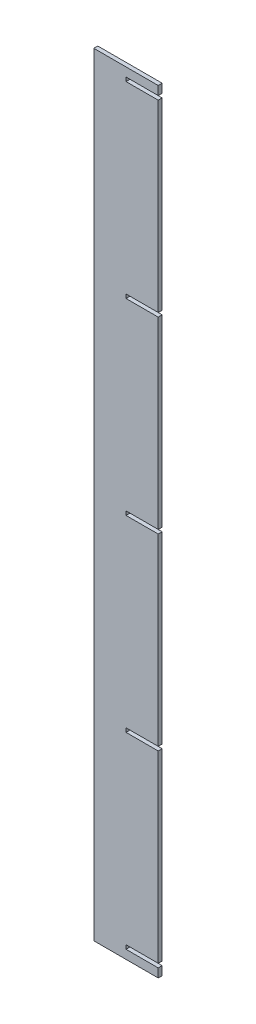
from build123d import *

# Parameters (mm, degrees)
BOSS_EXTRUDE1_DEPTH = 9.398


with BuildPart() as part:
    # Sketch1 → Boss-Extrude1 (new body)
    with BuildSketch(Plane.XY):
        Polygon((25084.546523942, 8828.751571885), (25084.546523942, 6999.951571885), (25236.946523942, 6999.951571885), (25236.946523942, 7020.652571885), (25160.746523942, 7020.652571885), (25160.746523942, 7030.050571885), (25236.946523942, 7030.050571885), (25236.946523942, 7465.152571885), (25160.746523942, 7465.152571885), (25160.746523942, 7474.550571885), (25236.946523942, 7474.550571885), (25236.946523942, 7909.652571885), (25160.746523942, 7909.652571885), (25160.746523942, 7919.050571885), (25236.946523942, 7919.050571885), (25236.946523942, 8354.152571885), (25160.746523942, 8354.152571885), (25160.746523942, 8363.550571885), (25236.946523942, 8363.550571885), (25236.946523942, 8798.652571885), (25160.746523942, 8798.652571885), (25160.746523942, 8808.050571885), (25236.946523942, 8808.050571885), (25236.946523942, 8828.751571885), align=None)
    extrude(amount=BOSS_EXTRUDE1_DEPTH)


solid = part.part
